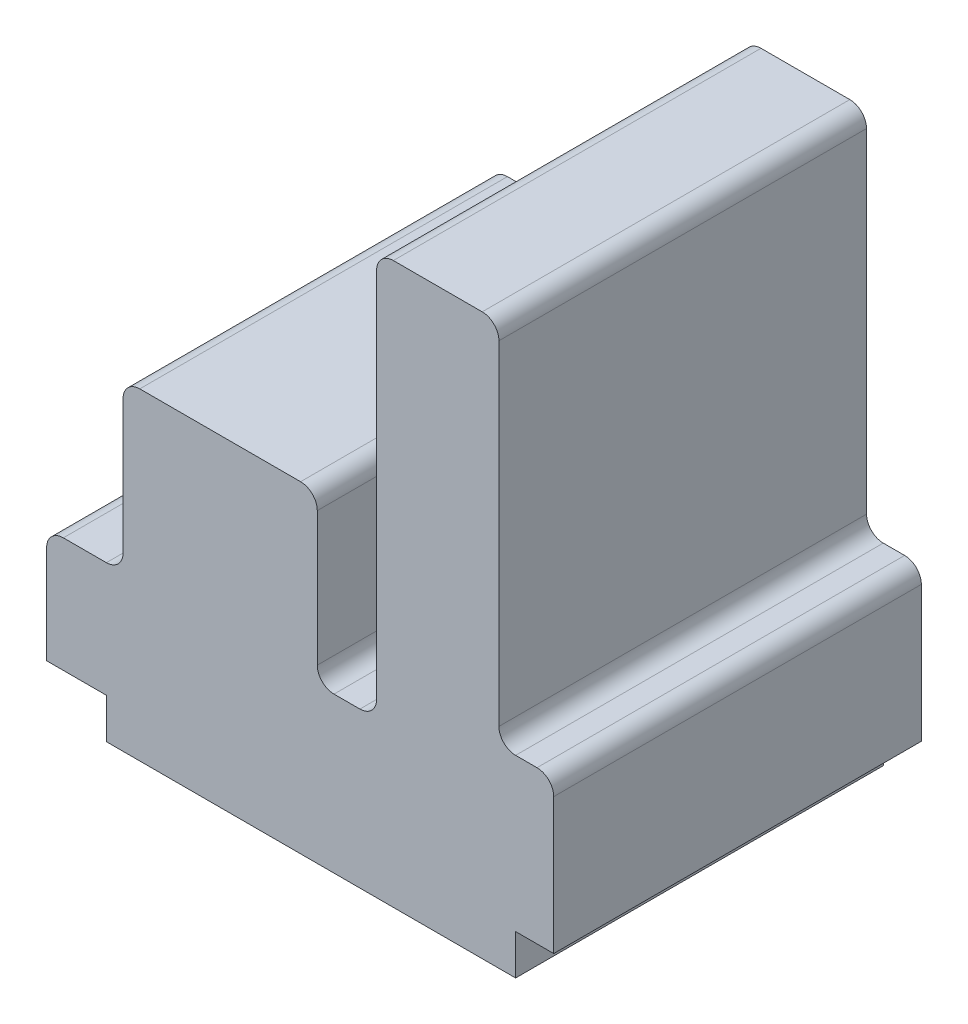
from build123d import *

# Parameters (mm, degrees)
Y_KSEKLIK_EKSTR_ZYON2_DEPTH = 66


with BuildPart() as part:
    # Çizim5 → Yükseklik-Ekstrüzyon2 (new body)
    with BuildSketch(Plane.XY):
        with BuildLine():
            Line((3, 27.837901934), (10.723277294, 27.837901934))
            ThreePointArc((10.723277294, 27.837901934), (12.844597638, 28.716581591), (13.723277294, 30.837901934))
            Line((13.723277294, 30.837901934), (13.723277294, 54.860494767))
            ThreePointArc((13.723277294, 54.860494767), (14.60195695, 56.98181511), (16.723277294, 57.860494767))
            Line((16.723277294, 57.860494767), (45.588223809, 57.860494767))
            ThreePointArc((45.588223809, 57.860494767), (47.709544152, 56.98181511), (48.588223809, 54.860494767))
            Line((48.588223809, 54.860494767), (48.588223809, 30.837901934))
            ThreePointArc((48.588223809, 30.837901934), (49.466903465, 28.716581591), (51.588223809, 27.837901934))
            Line((51.588223809, 27.837901934), (56.24140191, 27.837901934))
            ThreePointArc((56.24140191, 27.837901934), (58.362722254, 28.716581591), (59.24140191, 30.837901934))
            Line((59.24140191, 30.837901934), (59.24140191, 97.571673858))
            ThreePointArc((59.24140191, 97.571673858), (60.120081567, 99.692994202), (62.24140191, 100.571673858))
            Line((62.24140191, 100.571673858), (78.193405271, 100.571673858))
            ThreePointArc((78.193405271, 100.571673858), (80.314725615, 99.692994202), (81.193405271, 97.571673858))
            Line((81.193405271, 97.571673858), (81.193405271, 37.61719709))
            ThreePointArc((81.193405271, 37.61719709), (82.072084928, 35.495876747), (84.193405271, 34.61719709))
            Line((84.193405271, 34.61719709), (88.033262194, 34.61719709))
            ThreePointArc((88.033262194, 34.61719709), (90.154582538, 33.738517434), (91.033262194, 31.61719709))
            Line((91.033262194, 31.61719709), (91.033262194, 7.220315017))
            Line((91.033262194, 7.220315017), (84.193405271, 7.220315017))
            Line((84.193405271, 7.220315017), (84.193405271, 0))
            Line((84.193405271, 0), (10.723277294, 0))
            Line((10.723277294, 0), (10.723277294, 7.220315017))
            Line((10.723277294, 7.220315017), (0, 7.220315017))
            Line((0, 7.220315017), (0, 24.837901934))
            ThreePointArc((0, 24.837901934), (0.878679656, 26.959222278), (3, 27.837901934))
        make_face()
    extrude(amount=Y_KSEKLIK_EKSTR_ZYON2_DEPTH)


solid = part.part
